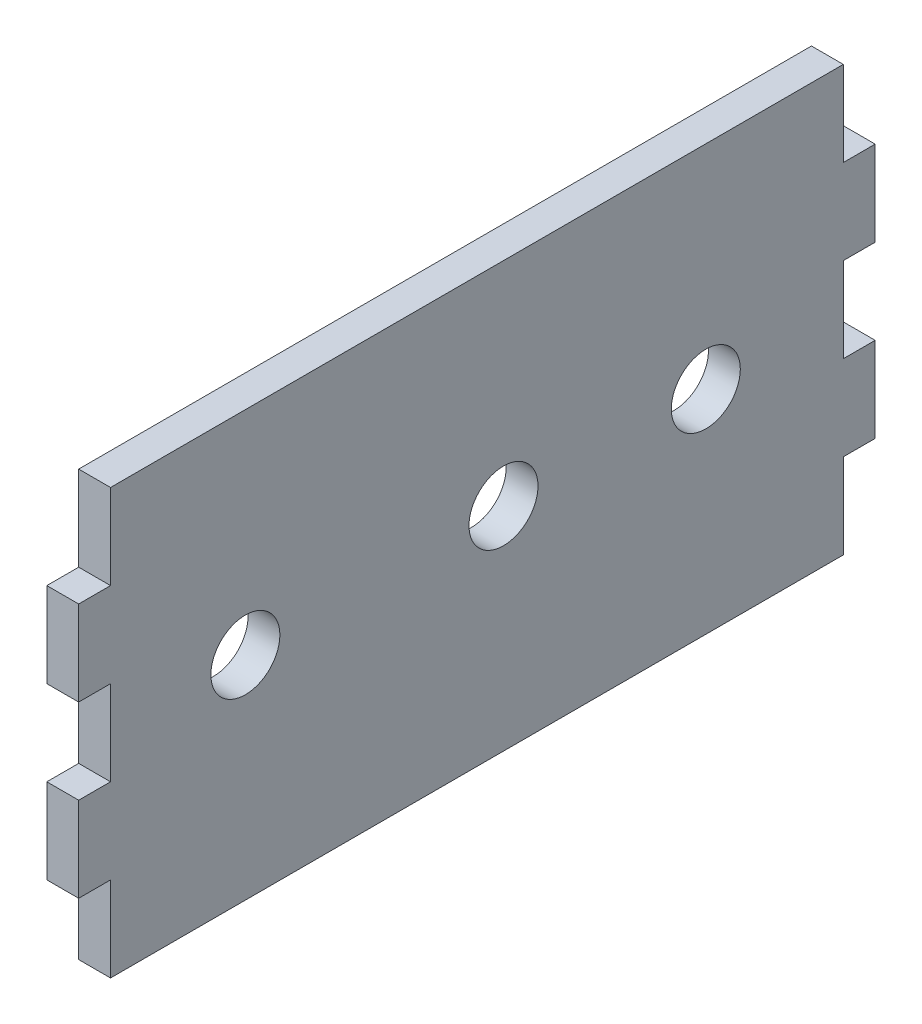
from build123d import *

# Parameters (mm, degrees)
CROQUIS1_W              = 150
CROQUIS1_H              = 80
SALIENTE_EXTRUIR1_DEPTH = 6
CROQUIS2_R              = 6.5
CORTAR_EXTRUIR1_DEPTH   = 6
CROQUIS3_W              = 6
CROQUIS3_H              = 16
CORTAR_EXTRUIR2_DEPTH   = 6


with BuildPart() as part:
    # Croquis1 → Saliente-Extruir1 (new body)
    with BuildSketch(Plane(origin=(0, 0, 0), x_dir=(0, 0, -1), z_dir=(1, 0, 0))):
        Rectangle(CROQUIS1_W, CROQUIS1_H)
    extrude(amount=SALIENTE_EXTRUIR1_DEPTH)

    # Croquis2 → Cortar-Extruir1 (cut)
    with BuildSketch(Plane(origin=(6, 0, 0), x_dir=(0, 0, -1), z_dir=(1, 0, 0))):
        with Locations((-43.61, 0)):
            Circle(CROQUIS2_R)
        with Locations((5, 0)):
            Circle(CROQUIS2_R)
        with Locations((43.1, 0)):
            Circle(CROQUIS2_R)
    extrude(amount=-CORTAR_EXTRUIR1_DEPTH, mode=Mode.SUBTRACT)

    # Croquis3 → Cortar-Extruir2 (cut)
    with BuildSketch(Plane(origin=(6, 0, 0), x_dir=(0, 0, -1), z_dir=(1, 0, 0))):
        with Locations((-72, 32)):
            Rectangle(CROQUIS3_W, CROQUIS3_H)
        with Locations((-72, -32)):
            Rectangle(CROQUIS3_W, CROQUIS3_H)
        with Locations((72, -32)):
            Rectangle(CROQUIS3_W, CROQUIS3_H)
        with Locations((72, 32)):
            Rectangle(CROQUIS3_W, CROQUIS3_H)
        with Locations((72, 0)):
            Rectangle(CROQUIS3_W, CROQUIS3_H)
        with Locations((-72, 0)):
            Rectangle(CROQUIS3_W, CROQUIS3_H)
    extrude(amount=-CORTAR_EXTRUIR2_DEPTH, mode=Mode.SUBTRACT)


solid = part.part
